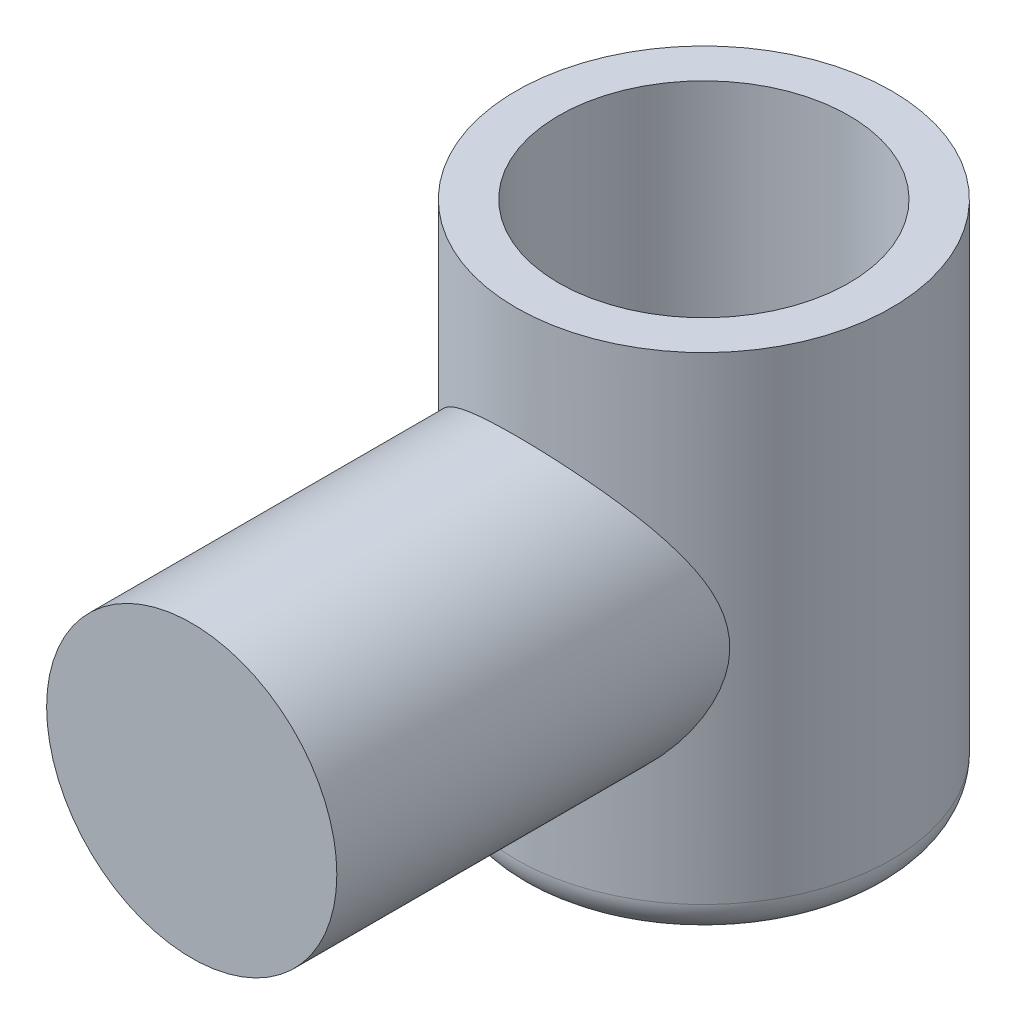
from build123d import *

# Parameters (mm, degrees)
SKETCH1_R           = 55
BOSS_EXTRUDE1_DEPTH = 75
SKETCH2_R           = 42.5
BOSS_EXTRUDE2_DEPTH = 150
FILLET2_R           = 10
SKETCH3_R           = 42.5
CUT_EXTRUDE1_DEPTH  = 110


with BuildPart() as part:
    # Sketch1 → Boss-Extrude1 (new body, symmetric)
    with BuildSketch(Plane(origin=(0, 0, 0), x_dir=(1, 0, 0), z_dir=(0, 1, 0))):
        Circle(SKETCH1_R)
    extrude(amount=BOSS_EXTRUDE1_DEPTH, both=True)

    # Sketch2 → Boss-Extrude2 (add)
    with BuildSketch(Plane.XY):
        Circle(SKETCH2_R)
    extrude(amount=BOSS_EXTRUDE2_DEPTH)

    # Fillet2
    fillet2_edges = [part.edges().sort_by_distance(p)[0] for p in [
        (-55, -75, 0),
    ]]
    fillet(fillet2_edges, radius=FILLET2_R)

    # Sketch3 → Cut-Extrude1 (cut)
    with BuildSketch(Plane(origin=(0, 0, 0), x_dir=(1, 0, 0), z_dir=(0, 1, 0))):
        Circle(SKETCH3_R)
    extrude(amount=CUT_EXTRUDE1_DEPTH, mode=Mode.SUBTRACT)


solid = part.part
